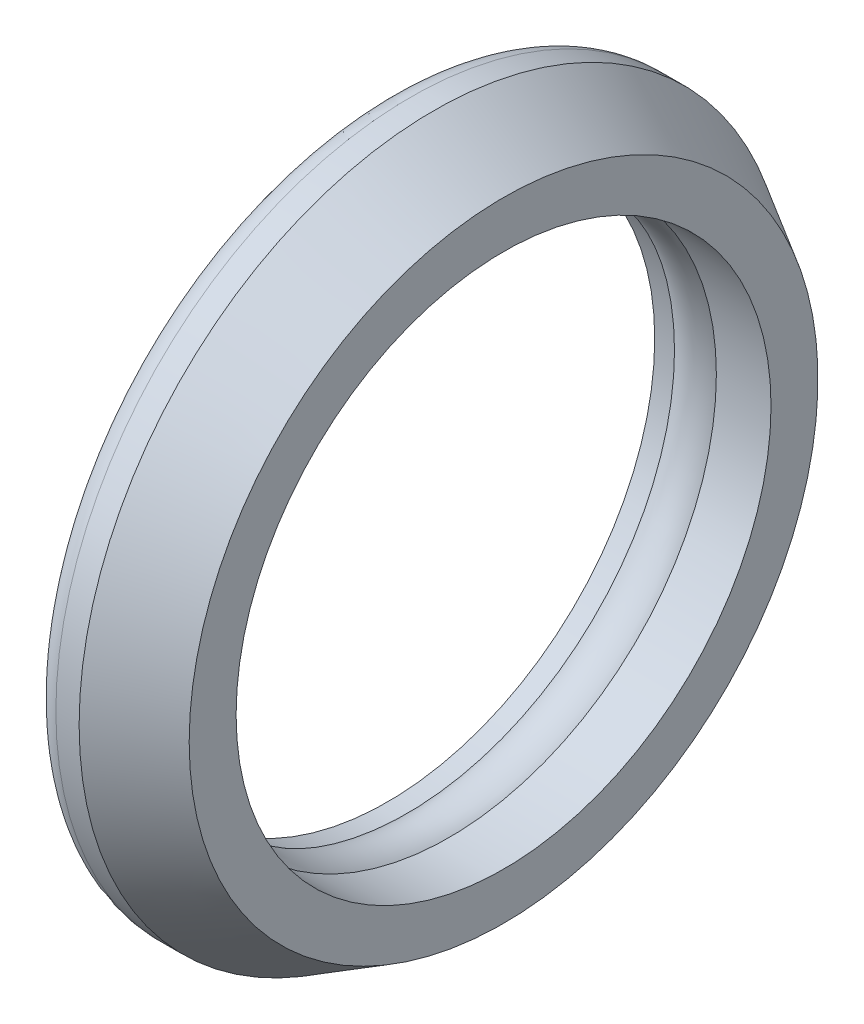
from build123d import *

# Parameters (mm, degrees)
FILLET1_R = 1


with BuildPart() as part:
    # Sketch1 → Revolve1 (revolve)
    with BuildSketch(Plane.XY):
        with BuildLine():
            Line((0, 11.5), (0, 15.25))
            Line((0, 15.25), (2, 15.25))
            Line((2, 15.25), (5, 13.517949192))
            Line((5, 13.517949192), (5, 11.5))
            Line((5, 11.5), (2.65, 11.5))
            ThreePointArc((2.65, 11.5), (1.75, 11.2), (0.85, 11.5))
            Line((0.85, 11.5), (0, 11.5))
        make_face()
    revolve(axis=Axis((0, 0, 0), (1, 0, 0)))

    # Fillet1
    fillet1_edges = [part.edges().sort_by_distance(p)[0] for p in [
        (0, -15.25, 0),
    ]]
    fillet(fillet1_edges, radius=FILLET1_R)


solid = part.part
